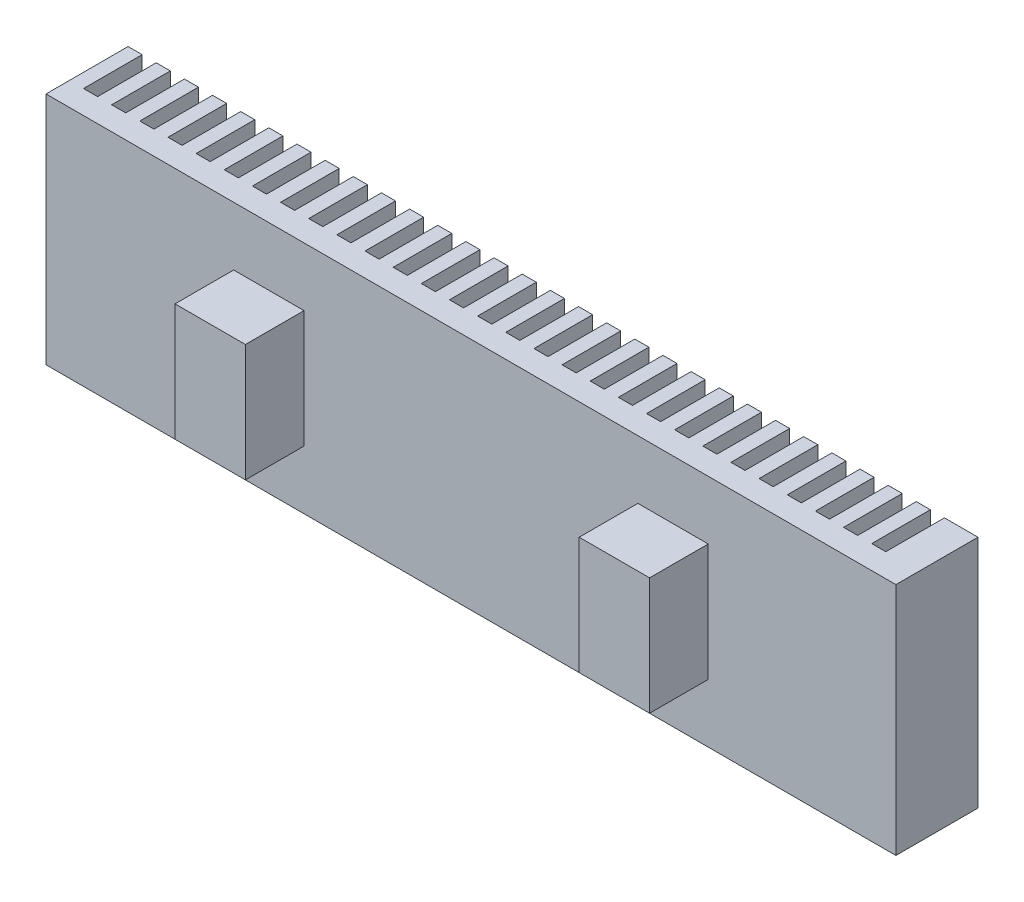
from build123d import *

# Parameters (mm, degrees)
SKETCH1_W           = 36.23
SKETCH1_H           = 3.5
BOSS_EXTRUDE1_DEPTH = 10
SKETCH3_W           = 3
SKETCH3_H           = 5
BOSS_EXTRUDE2_DEPTH = 2.5
SKETCH4_W           = 0.6
SKETCH4_H           = 2.5
CUT_EXTRUDE1_DEPTH  = 11
LPATTERN1_COUNT     = 29
LPATTERN1_PITCH     = 1.2


with BuildPart() as part:
    # Sketch1 → Boss-Extrude1 (new body)
    with BuildSketch(Plane(origin=(0, 0, 0), x_dir=(1, 0, 0), z_dir=(0, 1, 0))):
        with Locations((-18.115, 1.75)):
            Rectangle(SKETCH1_W, SKETCH1_H)
    extrude(amount=BOSS_EXTRUDE1_DEPTH)

    # Sketch3 → Boss-Extrude2 (add)
    with BuildSketch(Plane.XY):
        with Locations((-26.73, 5)):
            Rectangle(SKETCH3_W, SKETCH3_H)
        with Locations((-9.5, 5)):
            Rectangle(SKETCH3_W, SKETCH3_H)
    extrude(amount=BOSS_EXTRUDE2_DEPTH)

    # Sketch4 → Cut-Extrude1 (cut, through all)
    with BuildSketch(Plane(origin=(0, 10, 0), x_dir=(1, 0, 0), z_dir=(0, 1, 0))):
        with Locations((-35.33, 2.25)):
            Rectangle(SKETCH4_W, SKETCH4_H)
    cut_extrude1 = extrude(amount=-CUT_EXTRUDE1_DEPTH, mode=Mode.SUBTRACT)

    # LPattern1: Cut-Extrude1 ×29
    with Locations(*[(i * LPATTERN1_PITCH, 0, 0) for i in range(1, LPATTERN1_COUNT)]):
        add(cut_extrude1, mode=Mode.SUBTRACT)


solid = part.part
